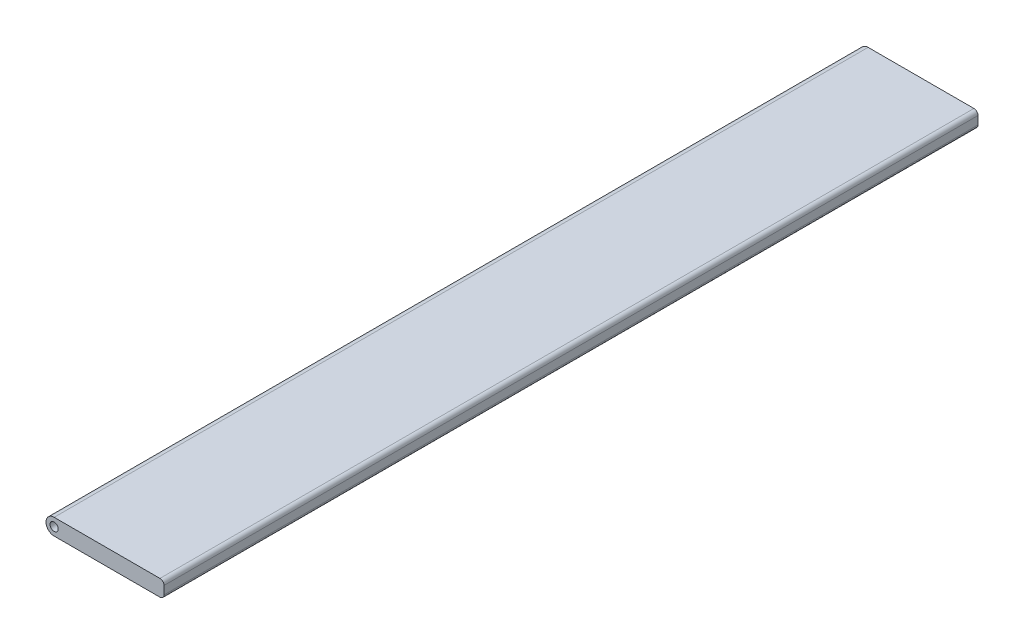
from build123d import *

# Parameters (mm, degrees)
EXTRUDE_1_DEPTH = 200


with BuildPart() as part:
    # 草图1 → 凸台-拉伸1 (new body)
    with BuildSketch(Plane.XY):
        with BuildLine():
            ThreePointArc((0, 2), (-2, 0), (0, -2))
            Line((0, -2), (0, -1))
            ThreePointArc((0, -1), (-1, 0), (0, 1))
            Line((0, 1), (0, 2))
        make_face()
        with BuildLine():
            Line((0, -1), (0, -2))
            ThreePointArc((0, -2), (1.414213562, -1.414213562), (2, 0))
            ThreePointArc((2, 0), (1.414213562, 1.414213562), (0, 2))
            Line((0, 2), (0, 1))
            ThreePointArc((0, 1), (0.707106781, 0.707106781), (1, 0))
            ThreePointArc((1, 0), (0.707106781, -0.707106781), (0, -1))
        make_face()
        with BuildLine():
            ThreePointArc((2, 0), (1.414213562, -1.414213562), (0, -2))
            Line((0, -2), (26, -2))
            ThreePointArc((26, -2), (26.707106781, -1.707106781), (27, -1))
            Line((27, -1), (27, 1))
            ThreePointArc((27, 1), (26.707106781, 1.707106781), (26, 2))
            Line((26, 2), (0, 2))
            ThreePointArc((0, 2), (1.414213562, 1.414213562), (2, 0))
        make_face()
    extrude(amount=EXTRUDE_1_DEPTH)


solid = part.part
